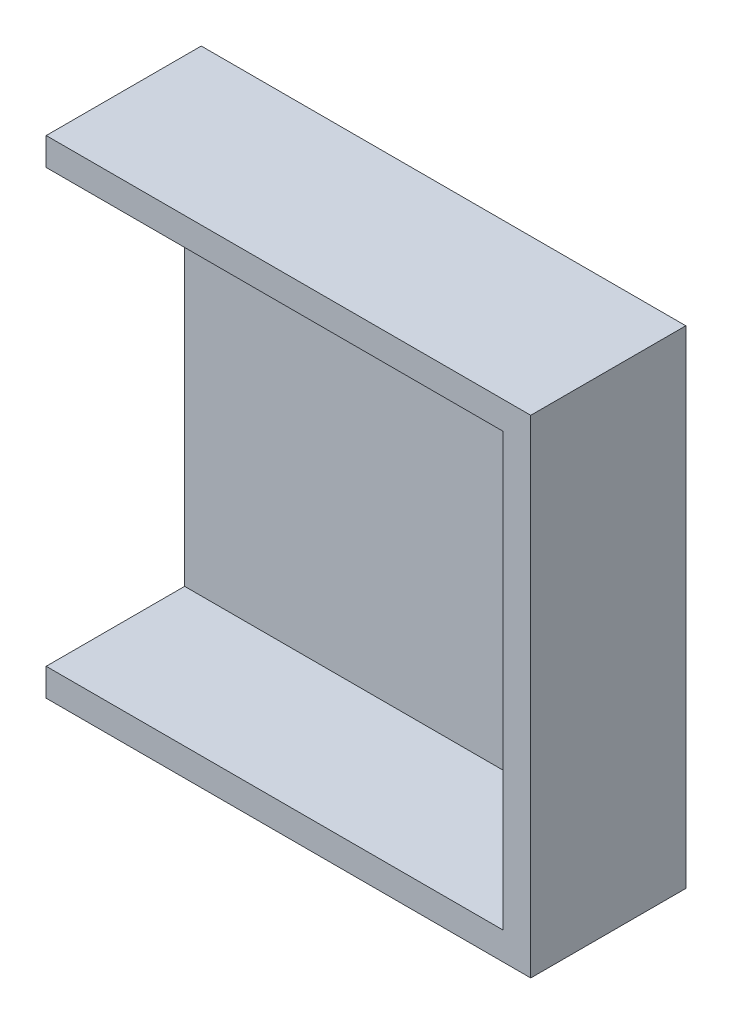
from build123d import *

# Parameters (mm, degrees)
CROQUIS1_W              = 35
CROQUIS1_H              = 35.2
SALIENTE_EXTRUIR1_DEPTH = 1.2
SALIENTE_EXTRUIR2_DEPTH = 10


with BuildPart() as part:
    # Croquis1 → Saliente-Extruir1 (new body)
    with BuildSketch(Plane.XY):
        with Locations((-46.090839695, -1.047328244)):
            Rectangle(CROQUIS1_W, CROQUIS1_H)
    extrude(amount=SALIENTE_EXTRUIR1_DEPTH)

    # Croquis2 → Saliente-Extruir2 (add)
    with BuildSketch(Plane.XY.offset(1.2)):
        Polygon((-63.590839695, 16.552671756), (-63.590839695, 14.552671756), (-30.590839695, 14.552671756), (-30.590839695, -16.647328244), (-63.590839695, -16.647328244), (-63.590839695, -18.647328244), (-28.590839695, -18.647328244), (-28.590839695, 16.552671756), align=None)
    extrude(amount=SALIENTE_EXTRUIR2_DEPTH)


solid = part.part
